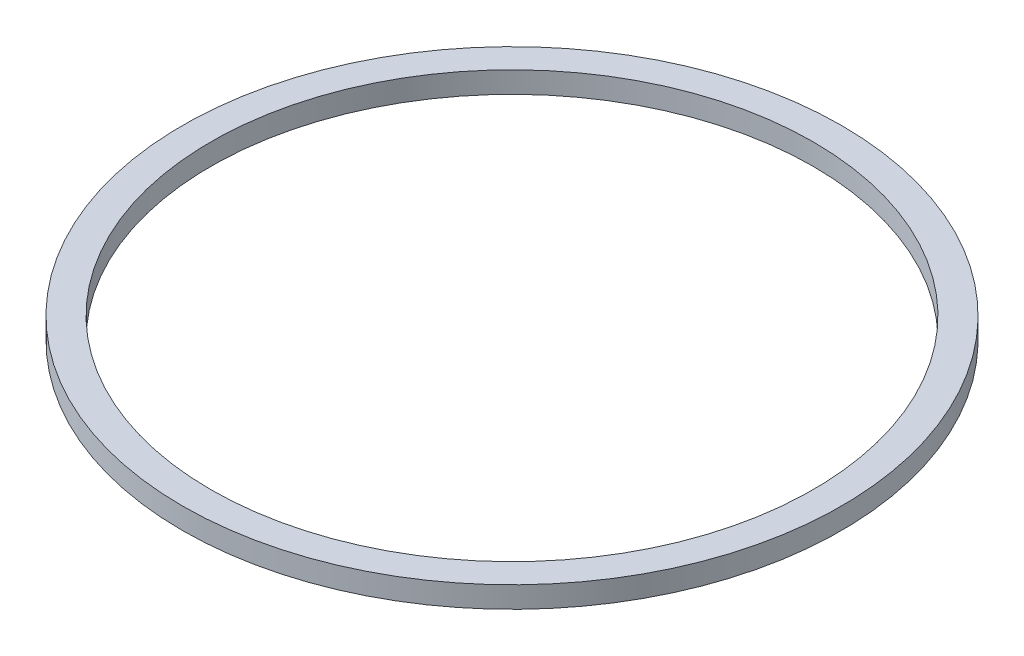
from build123d import *

# Parameters (mm, degrees)
SKETCH1_R           = 46.5
SKETCH1_R_2         = 42.5
BOSS_EXTRUDE1_DEPTH = 3


with BuildPart() as part:
    # Sketch1 → Boss-Extrude1 (new body)
    with BuildSketch(Plane(origin=(0, 0, 0), x_dir=(1, 0, 0), z_dir=(0, 1, 0))):
        Circle(SKETCH1_R)
        Circle(SKETCH1_R_2, mode=Mode.SUBTRACT)
    extrude(amount=BOSS_EXTRUDE1_DEPTH)


solid = part.part
